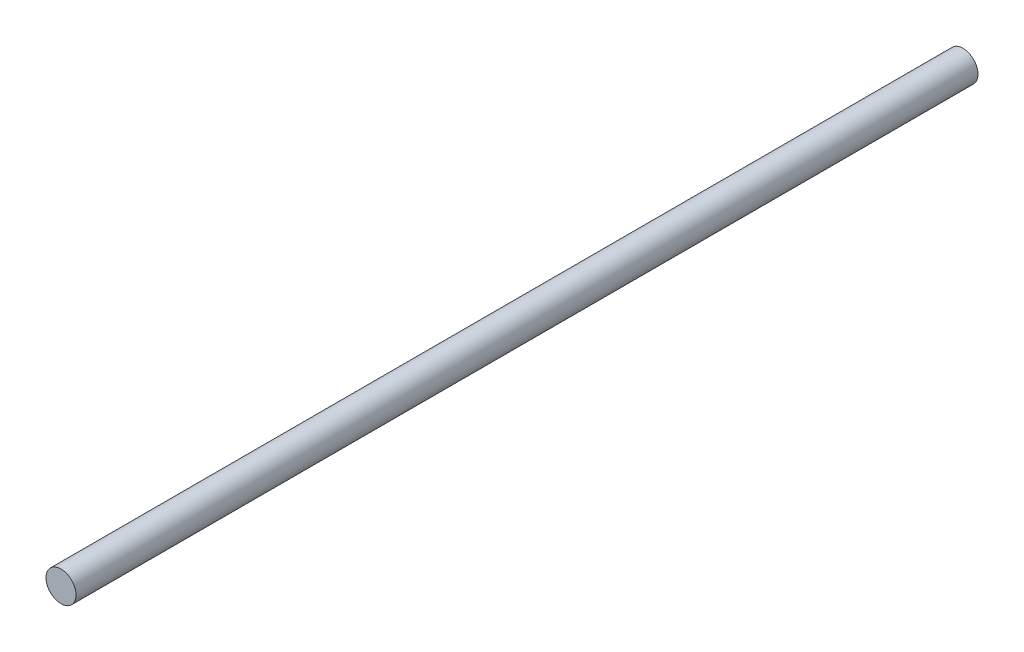
from build123d import *

# Parameters (mm, degrees)
SKETCH1_R           = 10
BOSS_EXTRUDE1_DEPTH = 600
SKETCH2_R           = 5
CUT_EXTRUDE1_DEPTH  = 150


with BuildPart() as part:
    # Sketch1 → Boss-Extrude1 (new body)
    with BuildSketch(Plane.XY):
        Circle(SKETCH1_R)
    extrude(amount=BOSS_EXTRUDE1_DEPTH)

    # Sketch2 → Cut-Extrude1 (cut)
    with BuildSketch(Plane(origin=(0, 0, 0), x_dir=(-1, 0, 0), z_dir=(0, 0, -1))):
        Circle(SKETCH2_R)
    extrude(amount=-CUT_EXTRUDE1_DEPTH, mode=Mode.SUBTRACT)


solid = part.part
